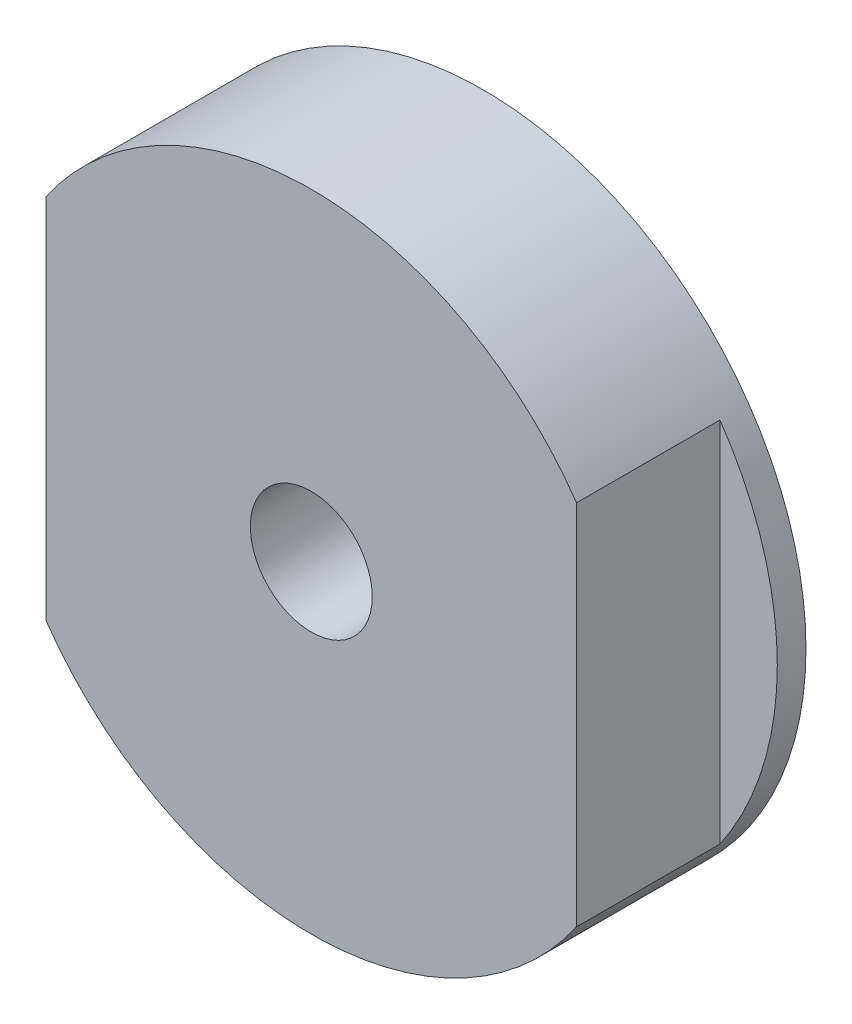
from build123d import *

# Parameters (mm, degrees)
SKETCH_1_R               = 22.5
EXTRUDE_1_DEPTH          = 12
CUT_EXTRUDE_1_DEPTH      = 10
HOLE_WIZARD_M10_1_D      = 8.5
HOLE_WIZARD_M10_1_DEPTH  = 24.5
HOLE_WIZARD_M10_1_TIP    = 2.553657631
PATTERN_CIRCULAR_1_COUNT = 4


with BuildPart() as part:
    # 草图1 → 凸台-拉伸1 (new body)
    with BuildSketch(Plane.XY):
        Circle(SKETCH_1_R)
    extrude(amount=EXTRUDE_1_DEPTH)

    # 草图2 → 切除-拉伸1 (cut)
    with BuildSketch(Plane.XY.offset(12)):
        with BuildLine():
            Line((-18.5, 12.806248475), (-18.5, -12.806248475))
            ThreePointArc((-18.5, -12.806248475), (-22.5, 0), (-18.5, 12.806248475))
        make_face()
        with BuildLine():
            Line((18.5, 12.806248475), (18.5, -12.806248475))
            ThreePointArc((18.5, -12.806248475), (22.5, 0), (18.5, 12.806248475))
        make_face()
    extrude(amount=-CUT_EXTRUDE_1_DEPTH, mode=Mode.SUBTRACT)

    # M10 螺纹孔1
    with Locations(Plane.XY.offset(12)):
        with Locations((0, 0)):
            Hole(HOLE_WIZARD_M10_1_D / 2, depth=HOLE_WIZARD_M10_1_DEPTH)
            with Locations((0, 0, -(HOLE_WIZARD_M10_1_DEPTH + HOLE_WIZARD_M10_1_TIP / 2))):  # 118° drill point
                Cone(0, HOLE_WIZARD_M10_1_D / 2, HOLE_WIZARD_M10_1_TIP, mode=Mode.SUBTRACT)

    # 草图7 → M4 螺纹孔2 (revolve, cut)
    with BuildSketch(Plane(origin=(-12.02081528, 12.02081528, 0), x_dir=(0, 1, 0), z_dir=(1, 0, 0))):
        Polygon((0, 0), (0, 11.091420021), (1.65, 10.1), (1.65, 0), align=None)
    hole_wizard_m4_2 = revolve(axis=Axis((-12.02081528, 12.02081528, -6.35), (0, 0, 1)), mode=Mode.SUBTRACT)

    # 阵列(圆周)1: M4 螺纹孔2 ×4 about axis
    pattern_circular_1_axis = Axis((0, 0, 0), (0, 0, 1))
    for i in range(1, PATTERN_CIRCULAR_1_COUNT):
        add(hole_wizard_m4_2.rotate(pattern_circular_1_axis, i * 360 / PATTERN_CIRCULAR_1_COUNT), mode=Mode.SUBTRACT)


solid = part.part
